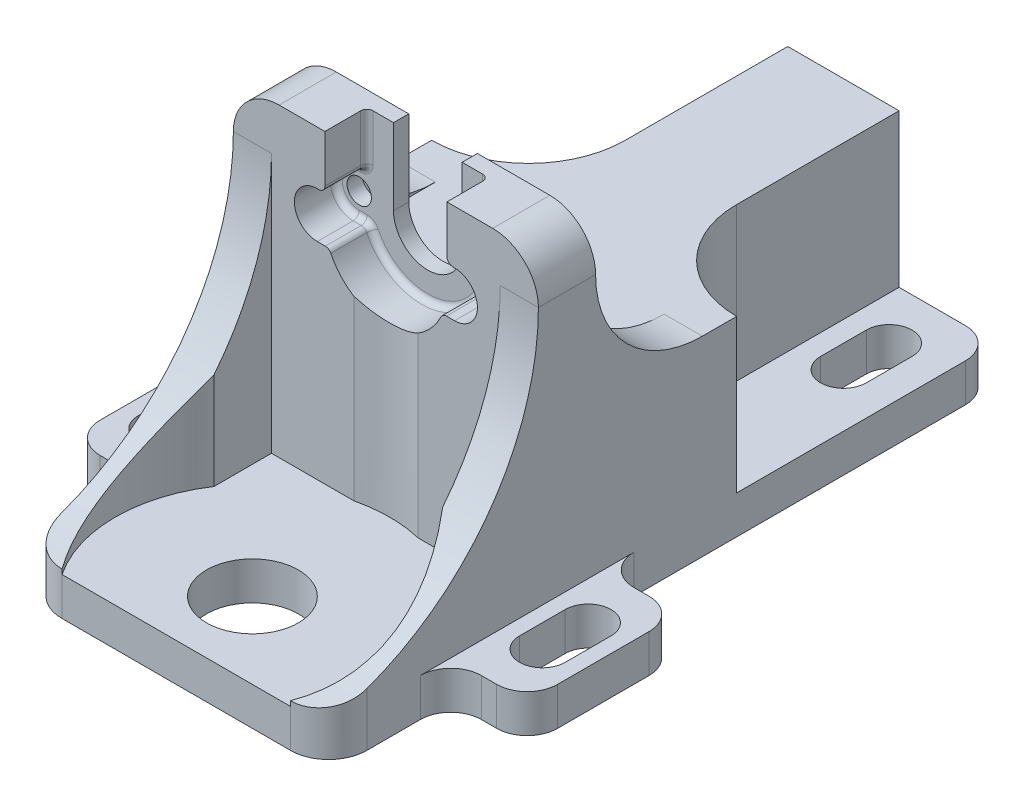
from build123d import *

# Parameters (mm, degrees)
SKETCH1_W           = 20
SKETCH1_H           = 50
BOSS_EXTRUDE1_DEPTH = 12.525
SKETCH2_W           = 20
SKETCH2_H           = 3.75
BOSS_EXTRUDE2_DEPTH = 10
CUT_EXTRUDE1_DEPTH  = 2.75
SKETCH5_R           = 0.8
CUT_EXTRUDE2_DEPTH  = 28.25
FILLET1_R           = 0.4
FILLET2_R           = 3
SKETCH6_W           = 20
SKETCH6_H           = 20
CUT_EXTRUDE3_DEPTH  = 10.025
SKETCH7_R           = 3.01
CUT_EXTRUDE4_DEPTH  = 3.5
BOSS_EXTRUDE3_DEPTH = 2.5
CUT_EXTRUDE6_DEPTH  = 10.025
SKETCH13_W          = 20
SKETCH13_H          = 6.249999854
CUT_EXTRUDE8_DEPTH  = 23.525
SKETCH14_W          = 30
SKETCH14_H          = 10
BOSS_EXTRUDE4_DEPTH = 2.5
CUT_EXTRUDE7_DEPTH  = 3.5
FILLET3_R           = 2
FILLET4_R           = 2.5
SKETCH15_R          = 9
CUT_EXTRUDE10_DEPTH = 21.025


with BuildPart() as part:
    # Sketch1 → Boss-Extrude1 (new body)
    with BuildSketch(Plane(origin=(0, 0, 0), x_dir=(1, 0, 0), z_dir=(0, 1, 0))):
        Rectangle(SKETCH1_W, SKETCH1_H)
    extrude(amount=BOSS_EXTRUDE1_DEPTH)

    # Sketch2 → Boss-Extrude2 (add)
    with BuildSketch(Plane(origin=(0, 12.525, 0), x_dir=(1, 0, 0), z_dir=(0, 1, 0))):
        with Locations((0, -3.125)):
            Rectangle(SKETCH2_W, SKETCH2_H)
    extrude(amount=BOSS_EXTRUDE2_DEPTH)

    # Sketch3 → Cut-Extrude1 (cut)
    with BuildSketch(Plane.XY.offset(5)):
        with BuildLine():
            Line((-4, 19.025), (-4, 22.525))
            Line((-4, 22.525), (4, 22.525))
            Line((4, 22.525), (4, 19.025))
            Line((4, 19.025), (4.5, 19.025))
            ThreePointArc((4.5, 19.025), (6, 17.525), (4.5, 16.025))
            Line((4.5, 16.025), (3.708099244, 16.025))
            ThreePointArc((3.708099244, 16.025), (0, 13.525), (-3.708099244, 16.025))
            Line((-3.708099244, 16.025), (-4.5, 16.025))
            ThreePointArc((-4.5, 16.025), (-6, 17.525), (-4.5, 19.025))
            Line((-4.5, 19.025), (-4, 19.025))
        make_face()
    extrude(amount=-CUT_EXTRUDE1_DEPTH, mode=Mode.SUBTRACT)

    # Sketch5 → Cut-Extrude2 (cut, through all)
    with BuildSketch(Plane.XY.offset(2.25)):
        with Locations((-4.5, 17.525)):
            Circle(SKETCH5_R)
        with Locations((4.5, 17.525)):
            Circle(SKETCH5_R)
        with BuildLine():
            Line((-2.25, 17.525), (-2.25, 22.525))
            Line((-2.25, 22.525), (2.25, 22.525))
            Line((2.25, 22.525), (2.25, 17.525))
            ThreePointArc((2.25, 17.525), (0, 15.275), (-2.25, 17.525))
        make_face()
    extrude(amount=-CUT_EXTRUDE2_DEPTH, mode=Mode.SUBTRACT)

    # Fillet1
    fillet1_edges = [part.edges().sort_by_distance(p)[0] for p in [
        (3.708099244, 16.025, 3.625),
        (-3.708099244, 16.025, 3.625),
        (-4, 19.025, 3.625),
        (4, 19.025, 3.625),
        (0, 13.525, 2.25),
        (-4.104049622, 16.025, 2.25),
        (-6, 17.525, 2.25),
        (-4.25, 19.025, 2.25),
        (-4, 20.775, 2.25),
        (4, 20.775, 2.25),
        (4.25, 19.025, 2.25),
        (6, 17.525, 2.25),
        (4.104049622, 16.025, 2.25),
    ]]
    fillet(fillet1_edges, radius=FILLET1_R)

    # Fillet2
    fillet2_edges = [part.edges().sort_by_distance(p)[0] for p in [
        (10, 22.525, 3.125),
        (-10, 22.525, 3.125),
    ]]
    fillet(fillet2_edges, radius=FILLET2_R)

    # Sketch6 → Cut-Extrude3 (cut)
    with BuildSketch(Plane(origin=(0, 12.525, 0), x_dir=(1, 0, 0), z_dir=(0, 1, 0))):
        with Locations((0, -15)):
            Rectangle(SKETCH6_W, SKETCH6_H)
    extrude(amount=-CUT_EXTRUDE3_DEPTH, mode=Mode.SUBTRACT)

    # Sketch7 → Cut-Extrude4 (cut, through all)
    with BuildSketch(Plane(origin=(0, 2.5, 0), x_dir=(1, 0, 0), z_dir=(0, 1, 0))):
        with Locations((0, -13.750000146)):
            Circle(SKETCH7_R)
    extrude(amount=-CUT_EXTRUDE4_DEPTH, mode=Mode.SUBTRACT)

    # Sketch8 → Boss-Extrude3 (add)
    with BuildSketch(Plane.ZY.offset(10)):
        with BuildLine():
            Line((5, 2.5), (22.025, 2.5))
            ThreePointArc((22.025, 2.5), (9.98650705, 7.48650705), (5, 19.525))
            Line((5, 19.525), (5, 2.5))
        make_face()
        with BuildLine():
            Line((1.25, 12.525), (-5.75, 12.525))
            ThreePointArc((-5.75, 12.525), (-0.800252532, 14.575252532), (1.25, 19.525))
            Line((1.25, 19.525), (1.25, 12.525))
        make_face()
    boss_extrude3 = extrude(amount=-BOSS_EXTRUDE3_DEPTH)

    # Sketch11 → Cut-Extrude6 (cut)
    with BuildSketch(Plane(origin=(0, 12.525, 0), x_dir=(1, 0, 0), z_dir=(0, 1, 0))):
        with BuildLine():
            Line((-3.65, 25), (-10, 25))
            Line((-10, 25), (-10, 8))
            ThreePointArc((-10, 8), (-5.509871939, 9.859871939), (-3.65, 14.35))
            Line((-3.65, 14.35), (-3.65, 25))
        make_face()
    cut_extrude6 = extrude(amount=-CUT_EXTRUDE6_DEPTH, mode=Mode.SUBTRACT)

    # Mirror1: Boss-Extrude3, Cut-Extrude6 across plane
    add(boss_extrude3.mirror(Plane(origin=(0, 0, 0), x_dir=(0, 0, 1), z_dir=(1, 0, 0))))
    add(cut_extrude6.mirror(Plane(origin=(0, 0, 0), x_dir=(0, 0, 1), z_dir=(1, 0, 0))), mode=Mode.SUBTRACT)

    # Sketch13 → Cut-Extrude8 (cut, through all)
    with BuildSketch(Plane.XZ):
        with Locations((0, 21.875000073)):
            Rectangle(SKETCH13_W, SKETCH13_H)
    extrude(amount=-CUT_EXTRUDE8_DEPTH, mode=Mode.SUBTRACT)

    # Sketch14 → Boss-Extrude4 (add)
    with BuildSketch(Plane.XZ):
        with Locations((0, 5.740000146)):
            Rectangle(SKETCH14_W, SKETCH14_H)
    extrude(amount=-BOSS_EXTRUDE4_DEPTH)

    # Sketch12 → Cut-Extrude7 (cut, through all)
    with BuildSketch(Plane(origin=(0, 2.5, 0), x_dir=(1, 0, 0), z_dir=(0, 1, 0))):
        with BuildLine():
            Line((-5, 21.5), (-5, 18.5))
            ThreePointArc((-5, 18.5), (-6.5, 17), (-8, 18.5))
            Line((-8, 18.5), (-8, 21.5))
            ThreePointArc((-8, 21.5), (-6.5, 23), (-5, 21.5))
        make_face()
        with BuildLine():
            Line((8, 21.5), (8, 18.5))
            ThreePointArc((8, 18.5), (6.5, 17), (5, 18.5))
            Line((5, 18.5), (5, 21.5))
            ThreePointArc((5, 21.5), (6.5, 23), (8, 21.5))
        make_face()
        with BuildLine():
            Line((-14, -7.240000146), (-14, -4.240000146))
            ThreePointArc((-14, -4.240000146), (-12.5, -2.740000146), (-11, -4.240000146))
            Line((-11, -4.240000146), (-11, -7.240000146))
            ThreePointArc((-11, -7.240000146), (-12.5, -8.740000146), (-14, -7.240000146))
        make_face()
        with BuildLine():
            Line((11, -7.240000146), (11, -4.240000146))
            ThreePointArc((11, -4.240000146), (12.5, -2.740000146), (14, -4.240000146))
            Line((14, -4.240000146), (14, -7.240000146))
            ThreePointArc((14, -7.240000146), (12.5, -8.740000146), (11, -7.240000146))
        make_face()
    extrude(amount=-CUT_EXTRUDE7_DEPTH, mode=Mode.SUBTRACT)

    # Fillet3
    fillet3_edges = [part.edges().sort_by_distance(p)[0] for p in [
        (-10, 1.25, -25),
        (10, 1.25, -25),
        (15, 1.25, 0.740000146),
        (-15, 1.25, 10.740000146),
        (-10, 1.25, 10.740000146),
        (10, 1.25, 10.740000146),
        (-15, 1.25, 0.740000146),
        (10, 1.25, 0.740000146),
        (-10, 1.25, 0.740000146),
        (15, 1.25, 10.740000146),
    ]]
    fillet(fillet3_edges, radius=FILLET3_R)

    # Fillet4
    fillet4_edges = [part.edges().sort_by_distance(p)[0] for p in [
        (10, 1.408982762, 18.750000146),
        (-10, 1.408982762, 18.750000146),
    ]]
    fillet(fillet4_edges, radius=FILLET4_R)

    # Sketch15 → Cut-Extrude10 (cut, through all)
    with BuildSketch(Plane(origin=(0, 2.5, 0), x_dir=(1, 0, 0), z_dir=(0, 1, 0))):
        with Locations((0, -13.750000146)):
            Circle(SKETCH15_R)
    extrude(amount=CUT_EXTRUDE10_DEPTH, mode=Mode.SUBTRACT)


solid = part.part
